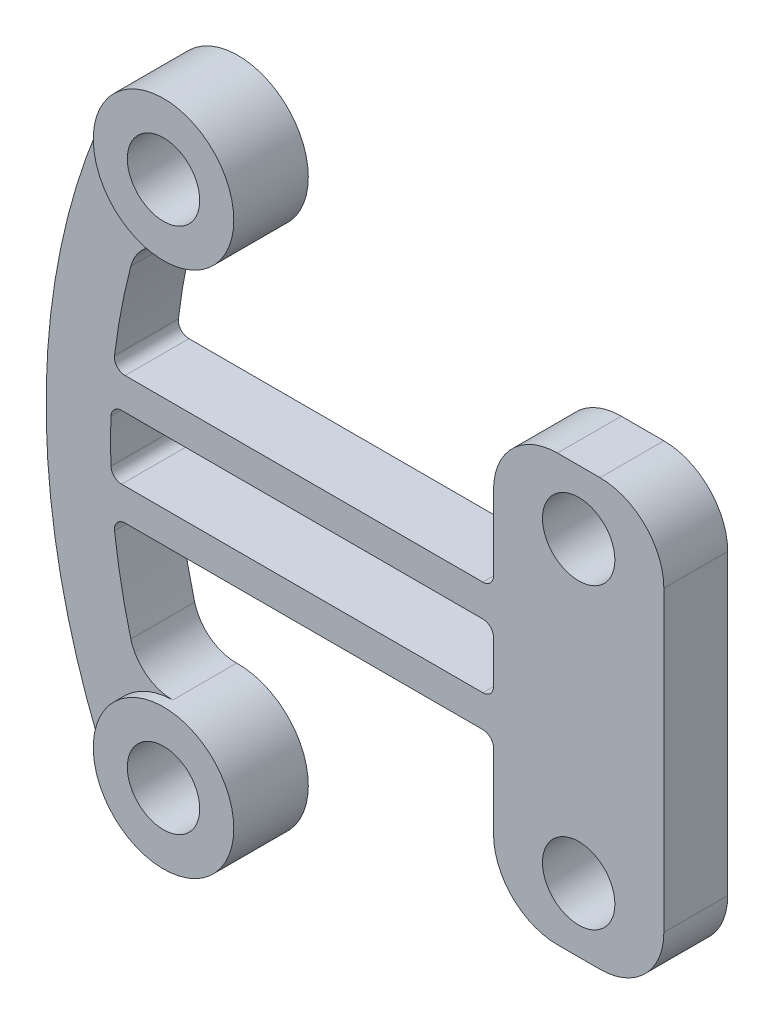
from build123d import *

# Parameters (mm, degrees)
BOSS_EXTRUDE1_DEPTH  = 3
SKETCH2_W            = 8
SKETCH2_H            = 3
BOSS_EXTRUDE2_DEPTH  = 7
SKETCH3_W            = 8
SKETCH3_H            = 3
BOSS_EXTRUDE3_DEPTH  = 7
SKETCH4_R            = 3.300094696
BOSS_EXTRUDE4_DEPTH  = 0.5
SKETCH5_R            = 3.300094696
BOSS_EXTRUDE5_DEPTH  = 0.5
CUT_EXTRUDE1_DEPTH   = 4
M3_CLEARANCE_HOLE2_D = 3.4
M3_CLEARANCE_HOLE1_D = 3.4
FILLET1_R            = 0.5
FILLET2_R            = 2
FILLET3_R            = 3


with BuildPart() as part:
    # Sketch1 → Boss-Extrude1 (new body)
    with BuildSketch(Plane(origin=(0, 0, 0), x_dir=(-1, 0, 0), z_dir=(0, 0, -1))):
        with BuildLine():
            Line((-16, 3), (-16, -3))
            Line((-16, -3), (9.864129683, -3))
            ThreePointArc((9.864129683, -3), (9.35323266, -6.252551424), (8.487341847, -9.429080919))
            ThreePointArc((8.487341847, -9.429080919), (3.884055388, -13.461974782), (9.996965881, -13.756600705))
            ThreePointArc((9.996965881, -13.756600705), (13.015220034, 0), (9.996965881, 13.756600705))
            ThreePointArc((9.996965881, 13.756600705), (3.884055388, 13.461974781), (8.487341847, 9.429080919))
            ThreePointArc((8.487341847, 9.429080919), (9.35323266, 6.252551424), (9.864129683, 3))
            Line((9.864129683, 3), (-16, 3))
        make_face()
    extrude(amount=-BOSS_EXTRUDE1_DEPTH)

    # Sketch2 → Boss-Extrude2 (add)
    with BuildSketch(Plane.XZ.offset(3)):
        with Locations((12, 1.5)):
            Rectangle(SKETCH2_W, SKETCH2_H)
    extrude(amount=BOSS_EXTRUDE2_DEPTH)

    # Sketch3 → Boss-Extrude3 (add)
    with BuildSketch(Plane(origin=(0, 3, 0), x_dir=(-1, 0, 0), z_dir=(0, 1, 0))):
        with Locations((-12, 1.5)):
            Rectangle(SKETCH3_W, SKETCH3_H)
    extrude(amount=BOSS_EXTRUDE3_DEPTH)

    # Sketch4 → Boss-Extrude4 (add)
    with BuildSketch(Plane.XY.offset(3)):
        with Locations((-7, 12.375)):
            Circle(SKETCH4_R)
    extrude(amount=BOSS_EXTRUDE4_DEPTH)

    # Sketch5 → Boss-Extrude5 (add)
    with BuildSketch(Plane.XY.offset(3)):
        with Locations((-7, -12.375)):
            Circle(SKETCH5_R)
    extrude(amount=BOSS_EXTRUDE5_DEPTH)

    # Sketch6 → Cut-Extrude1 (cut, through all)
    with BuildSketch(Plane.XY.offset(3)):
        with BuildLine():
            Line((8, 1.5), (-9.948163366, 1.5))
            ThreePointArc((-9.948163366, 1.5), (-9.985864188, 0), (-9.948163366, -1.5))
            Line((-9.948163366, -1.5), (8, -1.5))
            Line((8, -1.5), (8, 1.5))
        make_face()
    extrude(amount=-CUT_EXTRUDE1_DEPTH, mode=Mode.SUBTRACT)

    # M3 Clearance Hole2 (through all)
    with Locations(Plane(origin=(0, 0, 0), x_dir=(-1, 0, 0), z_dir=(0, 0, -1))):
        with Locations((-12, -7), (-12, 7)):
            Hole(M3_CLEARANCE_HOLE2_D / 2)

    # M3 Clearance Hole1 (through all)
    with Locations(Plane(origin=(0, 0, 0), x_dir=(-1, 0, 0), z_dir=(0, 0, -1))):
        with Locations((7, 12.375), (7, -12.375)):
            Hole(M3_CLEARANCE_HOLE1_D / 2)

    # Fillet1
    fillet1_edges = [part.edges().sort_by_distance(p)[0] for p in [
        (-9.864129683, 3, 1.5),
        (-9.864129683, -3, 1.5),
        (8, -3, 1.5),
        (8, 3, 1.5),
        (8, 1.5, 1.5),
        (8, -1.5, 1.5),
        (-9.948163366, -1.5, 1.5),
        (-9.948163366, 1.5, 1.5),
    ]]
    fillet(fillet1_edges, radius=FILLET1_R)

    # Fillet2
    fillet2_edges = [part.edges().sort_by_distance(p)[0] for p in [
        (-8.487341847, 9.429080919, 1.5),
        (-8.487341847, -9.429080919, 1.5),
    ]]
    fillet(fillet2_edges, radius=FILLET2_R)

    # Fillet3
    fillet3_edges = [part.edges().sort_by_distance(p)[0] for p in [
        (8, -10, 1.5),
        (16, -10, 1.5),
        (16, 10, 1.5),
        (8, 10, 1.5),
    ]]
    fillet(fillet3_edges, radius=FILLET3_R)


solid = part.part
